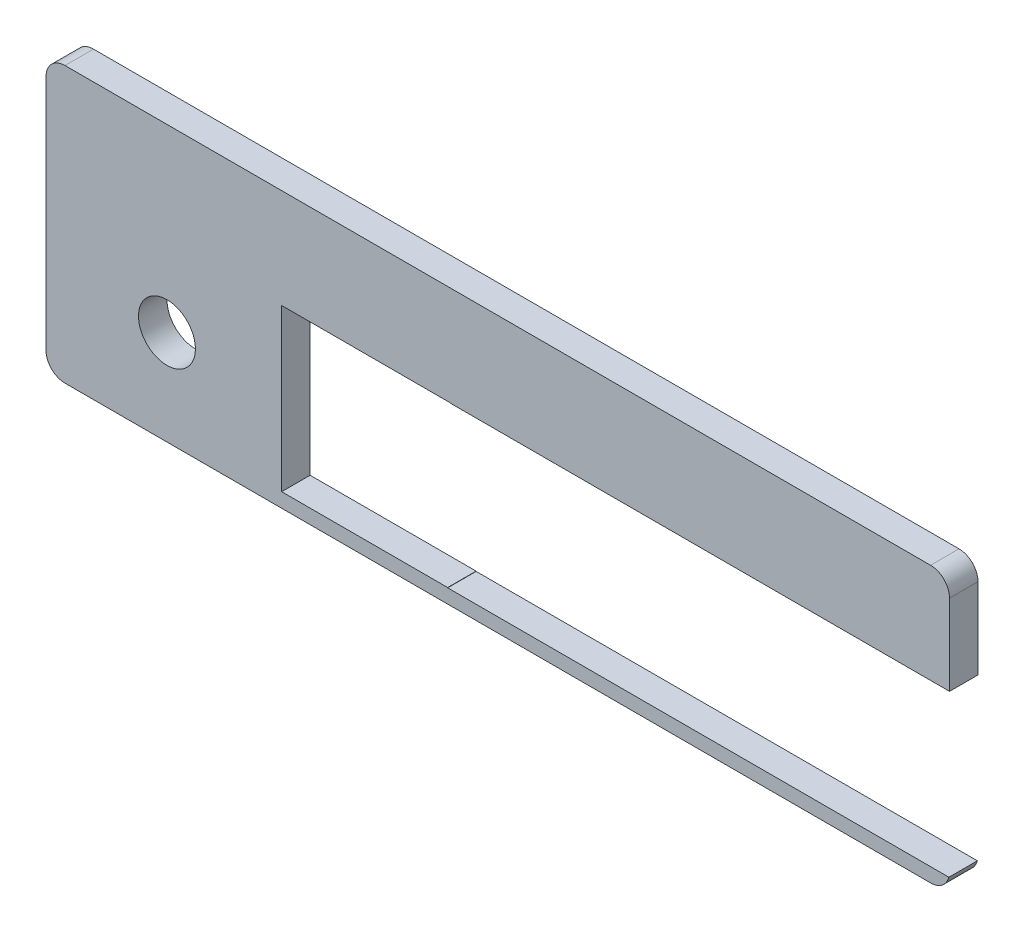
from build123d import *

# Parameters (mm, degrees)
SKETCH1_R           = 3
BOSS_EXTRUDE1_DEPTH = 3


with BuildPart() as part:
    # Sketch1 → Boss-Extrude1 (new body)
    with BuildSketch(Plane.XY):
        with BuildLine():
            ThreePointArc((46, 17.75), (45.414213562, 19.164213562), (44, 19.75))
            Line((44, 19.75), (-47.25, 19.75))
            ThreePointArc((-47.25, 19.75), (-48.664213562, 19.164213562), (-49.25, 17.75))
            Line((-49.25, 17.75), (-49.25, -7.25))
            ThreePointArc((-49.25, -7.25), (-48.664213562, -8.664213562), (-47.25, -9.25))
            Line((-47.25, -9.25), (44, -9.25))
            ThreePointArc((44, -9.25), (45.219142744, -8.835462384), (45.932904961, -7.763690971))
            Line((45.932904961, -7.763690971), (45.906437474, -7.763690971))
            Line((45.906437474, -7.763690971), (28.406437474, -7.763690971))
            Line((28.406437474, -7.763690971), (28.092497309, -7.763690971))
            Line((28.092497309, -7.763690971), (10.906437474, -7.763690971))
            Line((10.906437474, -7.763690971), (10.592497309, -7.763690971))
            Line((10.592497309, -7.763690971), (-6.907502691, -7.763690971))
            Line((-6.907502691, -7.763690971), (-6.907502691, -7.736309029))
            Line((-6.907502691, -7.736309029), (-24.406437474, -7.736309029))
            Line((-24.406437474, -7.736309029), (-24.406437474, 9.263690971))
            Line((-24.406437474, 9.263690971), (-6.592497309, 9.263690971))
            Line((-6.592497309, 9.263690971), (-6.592497309, 9.236309029))
            Line((-6.592497309, 9.236309029), (10.592497309, 9.236309029))
            Line((10.592497309, 9.236309029), (10.906437474, 9.236309029))
            Line((10.906437474, 9.236309029), (28.092497309, 9.236309029))
            Line((28.092497309, 9.236309029), (28.406437474, 9.236309029))
            Line((28.406437474, 9.236309029), (45.906437474, 9.236309029))
            Line((45.906437474, 9.236309029), (46, 9.236309029))
            Line((46, 9.236309029), (46, 17.75))
        make_face()
        with Locations((-36.5, 0.75)):
            Circle(SKETCH1_R, mode=Mode.SUBTRACT)
    extrude(amount=BOSS_EXTRUDE1_DEPTH)


solid = part.part
